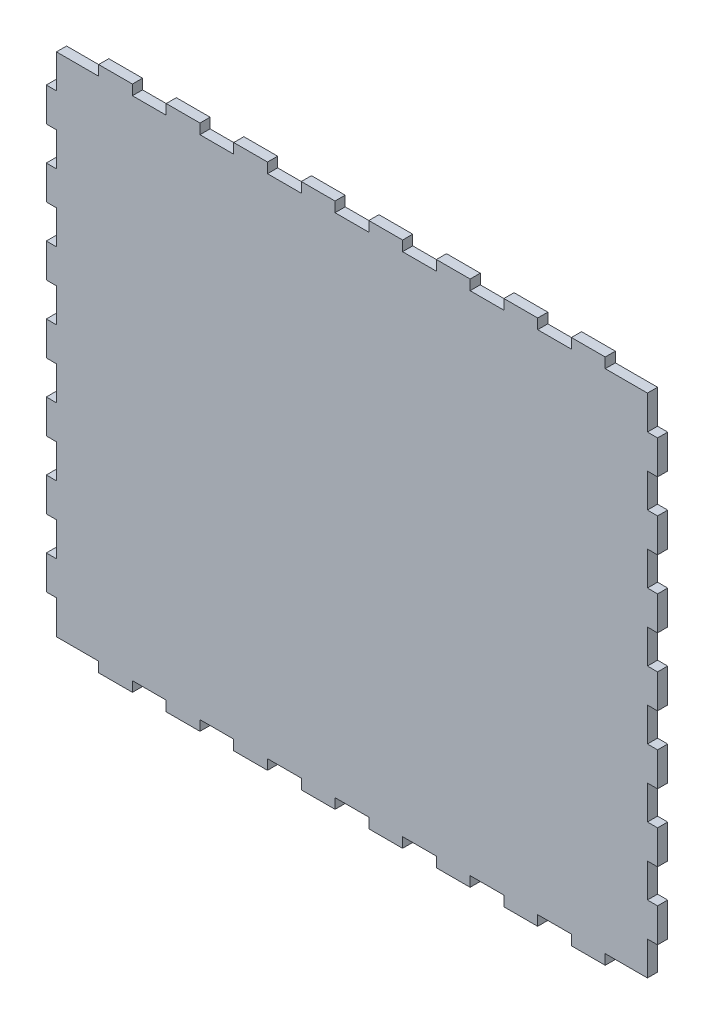
from build123d import *

# Parameters (mm, degrees)
BOSS_EXTRUDE1_DEPTH = 3


with BuildPart() as part:
    # Sketch1 → Boss-Extrude1 (new body)
    with BuildSketch(Plane.XY.offset(10)):
        Polygon((12.5, -13), (12.5, -10), (22.5, -10), (22.5, -13), (32.5, -13), (32.5, -10), (42.5, -10), (42.5, -13), (52.5, -13), (52.5, -10), (62.5, -10), (62.5, -13), (72.5, -13), (72.5, -10), (82.5, -10), (82.5, -13), (92.5, -13), (92.5, -10), (102.5, -10), (102.5, -13), (112.5, -13), (112.5, -10), (122.5, -10), (122.5, -13), (132.5, -13), (132.5, -10), (142.5, -10), (142.5, -13), (152.5, -13), (152.5, -10), (165, -10), (165, 0), (168, 0), (168, 10), (165, 10), (165, 20), (168, 20), (168, 30), (165, 30), (165, 40), (168, 40), (168, 50), (165, 50), (165, 60), (168, 60), (168, 70), (165, 70), (165, 80), (168, 80), (168, 90), (165, 90), (165, 100), (168, 100), (168, 110), (165, 110), (165, 120), (168, 120), (168, 130), (165, 130), (165, 140), (152.5, 140), (152.5, 143), (142.5, 143), (142.5, 140), (132.5, 140), (132.5, 143), (122.5, 143), (122.5, 140), (112.5, 140), (112.5, 143), (102.5, 143), (102.5, 140), (92.5, 140), (92.5, 143), (82.5, 143), (82.5, 140), (72.5, 140), (72.5, 143), (62.5, 143), (62.5, 140), (52.5, 140), (52.5, 143), (42.5, 143), (42.5, 140), (32.5, 140), (32.5, 143), (22.5, 143), (22.5, 140), (12.5, 140), (12.5, 143), (2.5, 143), (2.5, 140), (-10, 140), (-10, 130), (-13, 130), (-13, 120), (-10, 120), (-10, 110), (-13, 110), (-13, 100), (-10, 100), (-10, 90), (-13, 90), (-13, 80), (-10, 80), (-10, 70), (-13, 70), (-13, 60), (-10, 60), (-10, 50), (-13, 50), (-13, 40), (-10, 40), (-10, 30), (-13, 30), (-13, 20), (-10, 20), (-10, 10), (-13, 10), (-13, 0), (-10, 0), (-10, -10), (2.5, -10), (2.5, -13), align=None)
    extrude(amount=BOSS_EXTRUDE1_DEPTH)


solid = part.part
